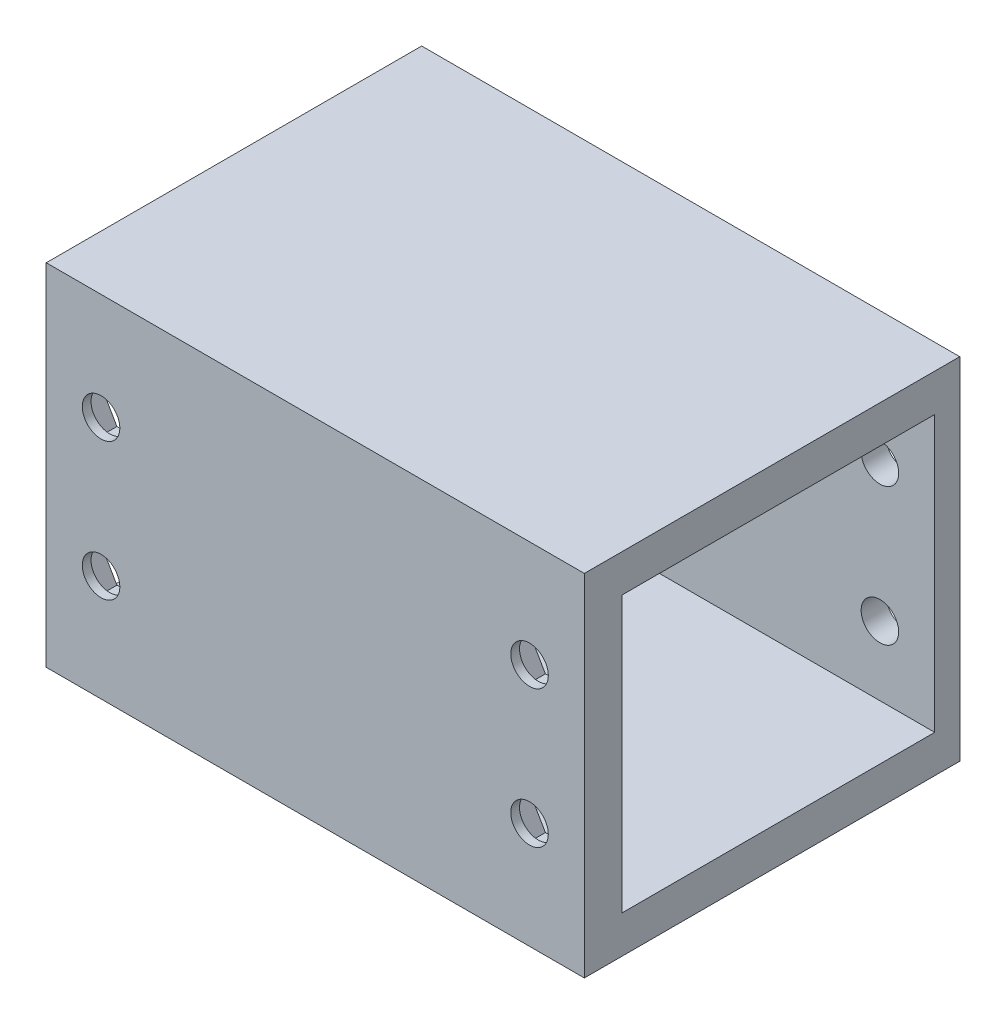
from build123d import *

# Parameters (mm, degrees)
SKETCH19_W          = 30
SKETCH19_H          = 28
SKETCH19_W_2        = 25
SKETCH19_H_2        = 22
BOSS_EXTRUDE1_DEPTH = 43
SKETCH30_R          = 1.5
CUT_EXTRUDE2_DEPTH  = 31
CUT_EXTRUDE4_DEPTH  = 2.3


with BuildPart() as part:
    # Sketch19 → Boss-Extrude1 (new body)
    with BuildSketch(Plane(origin=(0, 0, 0), x_dir=(0, 0, -1), z_dir=(1, 0, 0))):
        with Locations((1, -10)):
            Rectangle(SKETCH19_W, SKETCH19_H)
        with Locations((1.5, -10)):
            Rectangle(SKETCH19_W_2, SKETCH19_H_2, mode=Mode.SUBTRACT)
    extrude(amount=-BOSS_EXTRUDE1_DEPTH)

    # Sketch30 → Cut-Extrude2 (cut, through all)
    with BuildSketch(Plane.XY.offset(14)):
        with Locations((-38.62, -4.508713144)):
            Circle(SKETCH30_R)
        with Locations((-4.38, -4.508713144)):
            Circle(SKETCH30_R)
        with Locations((-4.38, -15.491286856)):
            Circle(SKETCH30_R)
        with Locations((-38.62, -15.491286856)):
            Circle(SKETCH30_R)
    extrude(amount=-CUT_EXTRUDE2_DEPTH, mode=Mode.SUBTRACT)

    # Sketch31 → Cut-Extrude4 (cut)
    with BuildSketch(Plane(origin=(0, 0, 11), x_dir=(-1, 0, 0), z_dir=(0, 0, -1))):
        Polygon((42.084101615, -4.508713144), (40.352050808, -1.508713144), (36.887949192, -1.508713144), (35.155898385, -4.508713144), (36.887949192, -7.508713144), (40.352050808, -7.508713144), align=None)
        Polygon((7.844101615, -4.508713144), (6.112050808, -1.508713144), (2.647949192, -1.508713144), (0.915898385, -4.508713144), (2.647949192, -7.508713144), (6.112050808, -7.508713144), align=None)
        Polygon((7.844101615, -15.491286856), (6.112050808, -12.491286856), (2.647949192, -12.491286856), (0.915898385, -15.491286856), (2.647949192, -18.491286856), (6.112050808, -18.491286856), align=None)
        Polygon((42.084101615, -15.491286856), (40.352050808, -12.491286856), (36.887949192, -12.491286856), (35.155898385, -15.491286856), (36.887949192, -18.491286856), (40.352050808, -18.491286856), align=None)
    extrude(amount=-CUT_EXTRUDE4_DEPTH, mode=Mode.SUBTRACT)


solid = part.part
